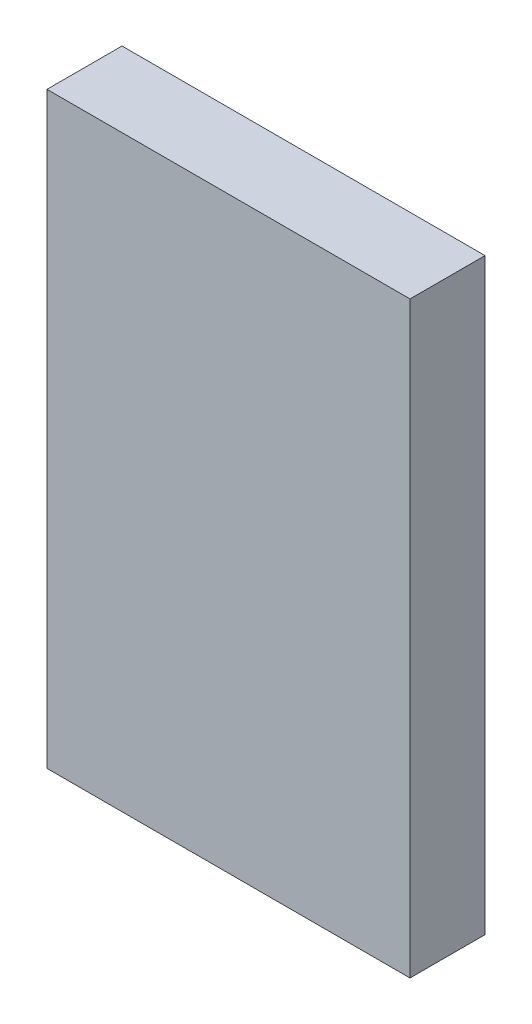
from build123d import *

# Parameters (mm, degrees)
SKETCH2_W           = 38.1
SKETCH2_H           = 7.874
BOSS_EXTRUDE1_DEPTH = 61.722


with BuildPart() as part:
    # Sketch2 → Boss-Extrude1 (new body)
    with BuildSketch(Plane(origin=(0, 0, 0), x_dir=(1, 0, 0), z_dir=(0, 1, 0))):
        Rectangle(SKETCH2_W, SKETCH2_H)
    extrude(amount=BOSS_EXTRUDE1_DEPTH)


solid = part.part
